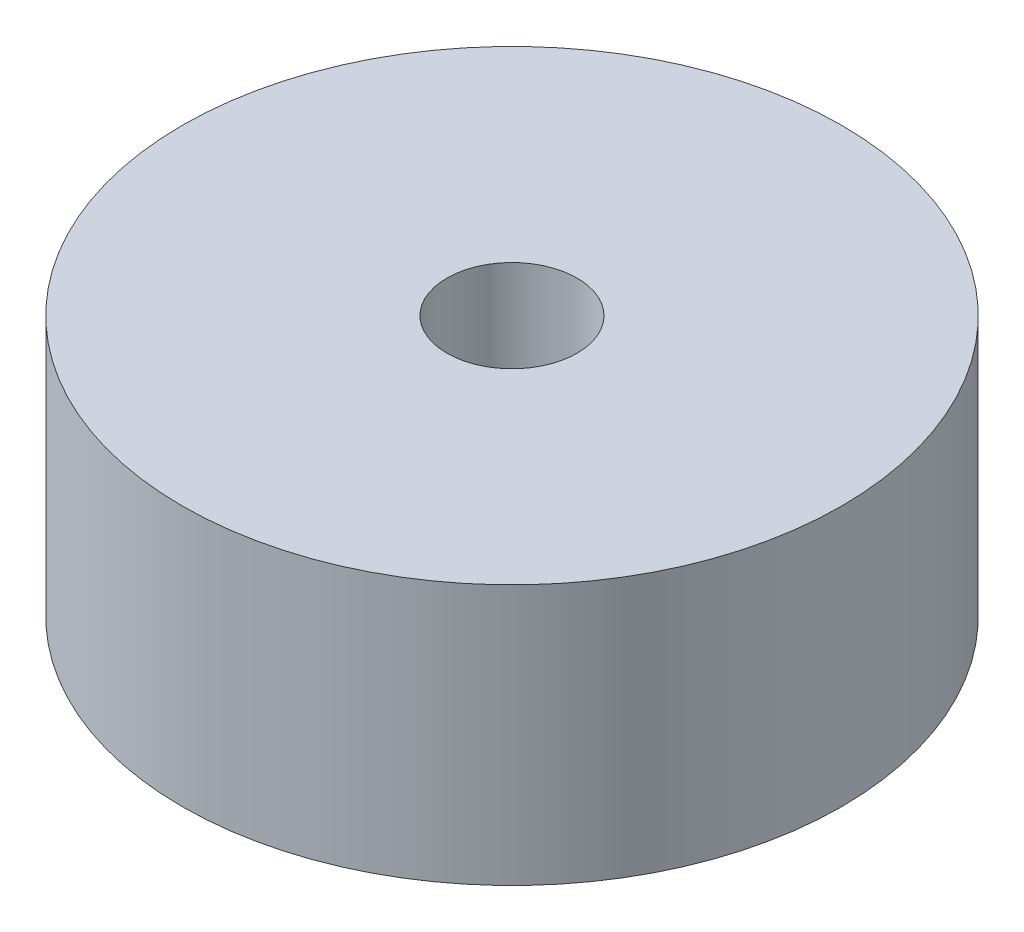
from build123d import *

# Parameters (mm, degrees)
SKETCH1_R           = 8.0391
SKETCH1_R_2         = 1.5875
BOSS_EXTRUDE1_DEPTH = 6.35


with BuildPart() as part:
    # Sketch1 → Boss-Extrude1 (new body)
    with BuildSketch(Plane(origin=(0, 0, 0), x_dir=(1, 0, 0), z_dir=(0, 1, 0))):
        Circle(SKETCH1_R)
        Circle(SKETCH1_R_2, mode=Mode.SUBTRACT)
    extrude(amount=BOSS_EXTRUDE1_DEPTH)


solid = part.part
